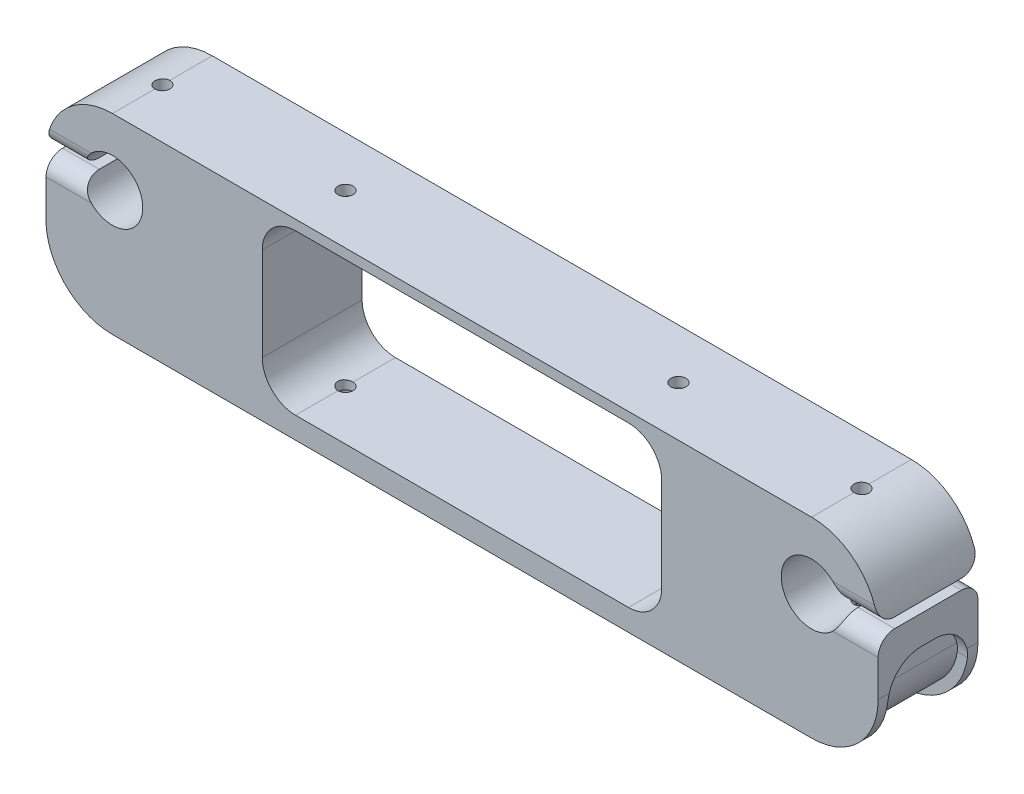
from build123d import *

# Parameters (mm, degrees)
SKETCH1_R               = 9.1
SKETCH1_R_2             = 4.125
BOSS_EXTRUDE1_DEPTH     = 30
CUT_EXTRUDE1_DEPTH      = 1
CUT_EXTRUDE1_DEPTH_BACK = 31
CUT_EXTRUDE2_DEPTH      = 12
FILLET1_R               = 10
FILLET1_OF_MIRROR1_R    = 10
SKETCH4_W               = 30
SKETCH4_H               = 3
CUT_EXTRUDE_THIN1_DEPTH = 18
FILLET2_R               = 5
SKETCH5_R               = 2.25
CUT_EXTRUDE3_DEPTH      = 60
CUT_EXTRUDE5_DEPTH      = 23
CUT_EXTRUDE6_START      = -23
SKETCH8_R               = 2.25
CUT_EXTRUDE6_DEPTH      = 100
FILLET2_OF_MIRROR2_R    = 5
SKETCH9_R               = 6.365755214
SKETCH9_R_2             = 7.364808268
BOSS_EXTRUDE2_DEPTH     = 3
SKETCH10_R              = 3.75
CUT_EXTRUDE7_DEPTH      = 4


with BuildPart() as part:
    # Sketch1 → Boss-Extrude1 (new body)
    with BuildSketch(Plane.XY):
        with BuildLine():
            Line((100.911119666, -31.68477204), (-108.97947751, -31.68477204))
            ThreePointArc((-108.97947751, -31.68477204), (-122.680198233, -26.254955692), (-128.941679221, -12.913797207))
            Line((-128.941679221, -12.913797207), (-128.941679221, 4.586502121))
            ThreePointArc((-128.941679221, 4.586502121), (-123.549540016, 19.516057921), (-108.979459083, 25.81522796))
            Line((-108.979459083, 25.81522796), (101.020540917, 25.81522796))
            ThreePointArc((101.020540917, 25.81522796), (115.16267654, 19.957363584), (121.020540917, 5.81522796))
            Line((121.020540917, 5.81522796), (121.020540917, -11.685071367))
            ThreePointArc((121.020540917, -11.685071367), (115.123937227, -25.865840476), (100.911119666, -31.68477204))
        make_face()
        with Locations((-108.979459083, 5.81522796)):
            Circle(SKETCH1_R, mode=Mode.SUBTRACT)
        with Locations((-83.979459083, 13.81522796)):
            Circle(SKETCH1_R_2, mode=Mode.SUBTRACT)
        with Locations((76.020540917, 13.81522796)):
            Circle(SKETCH1_R_2, mode=Mode.SUBTRACT)
        with Locations((101.020540917, 5.81522796)):
            Circle(SKETCH1_R, mode=Mode.SUBTRACT)
    extrude(amount=BOSS_EXTRUDE1_DEPTH)

    # Sketch2 → Cut-Extrude1 (cut, two sides)
    with BuildSketch(Plane(origin=(0, 0, 0), x_dir=(-1, 0, 0), z_dir=(0, 0, -1))) as cut_extrude1_sk:
        with BuildLine():
            Line((-46.020540917, -25.18477204), (53.979459083, -25.18477204))
            ThreePointArc((53.979459083, -25.18477204), (61.050526895, -22.255839852), (63.979459083, -15.18477204))
            Line((63.979459083, -15.18477204), (63.979459083, 12.81522796))
            ThreePointArc((63.979459083, 12.81522796), (61.050526895, 19.886295772), (53.979459083, 22.81522796))
            Line((53.979459083, 22.81522796), (-46.020540917, 22.81522796))
            ThreePointArc((-46.020540917, 22.81522796), (-53.091608729, 19.886295772), (-56.020540917, 12.81522796))
            Line((-56.020540917, 12.81522796), (-56.020540917, -15.18477204))
            ThreePointArc((-56.020540917, -15.18477204), (-53.091608729, -22.255839852), (-46.020540917, -25.18477204))
        make_face()
    extrude(amount=CUT_EXTRUDE1_DEPTH, mode=Mode.SUBTRACT)
    extrude(cut_extrude1_sk.sketch, amount=-CUT_EXTRUDE1_DEPTH_BACK, mode=Mode.SUBTRACT)

    # Sketch3 → Cut-Extrude2 (cut, symmetric)
    with BuildSketch(Plane(origin=(0, 0, 15), x_dir=(-1, 0, 0), z_dir=(0, 0, -1))):
        with BuildLine():
            Line((-121.020540917, -4.31328929), (-121.020540917, -11.685071367))
            ThreePointArc((-121.020540917, -11.685071367), (-115.123937227, -25.865840476), (-100.911119666, -31.68477204))
            Line((-100.911119666, -31.68477204), (-56.020540917, -31.68477204))
            Line((-56.020540917, -31.68477204), (-56.020540917, -28.68477204))
            Line((-56.020540917, -28.68477204), (-100.919659575, -28.68477204))
            ThreePointArc((-100.919659575, -28.68477204), (-113.005636185, -23.741500831), (-118.020540917, -11.685071367))
            Line((-118.020540917, -11.685071367), (-118.020540917, -4.31328929))
            Line((-118.020540917, -4.31328929), (-121.020540917, -4.31328929))
        make_face()
    cut_extrude2 = extrude(amount=CUT_EXTRUDE2_DEPTH, both=True, mode=Mode.SUBTRACT)

    # Fillet1
    fillet1_edges = [part.edges().sort_by_distance(p)[0] for p in [
        (119.520540917, -4.31328929, 3),
        (119.520540917, -4.31328929, 27),
        (56.020540917, -30.18477204, 3),
        (56.020540917, -30.18477204, 27),
    ]]
    fillet(fillet1_edges, radius=FILLET1_R)

    # Mirror1: Cut-Extrude2 across plane
    add(cut_extrude2.mirror(Plane(origin=(-3.979459083, 0, 0), x_dir=(0, 0, 1), z_dir=(1, 0, 0))), mode=Mode.SUBTRACT)

    # Fillet1 of Mirror1
    fillet1_of_mirror1_edges = [part.edges().sort_by_distance(p)[0] for p in [
        (-127.479459083, -4.31328929, 3),
        (-127.479459083, -4.31328929, 27),
        (-63.979459083, -30.18477204, 3),
        (-63.979459083, -30.18477204, 27),
    ]]
    fillet(fillet1_of_mirror1_edges, radius=FILLET1_OF_MIRROR1_R)

    # Sketch4 → Cut-Extrude-Thin1 (cut)
    with BuildSketch(Plane(origin=(121.020540917, 0, 0), x_dir=(0, 0, -1), z_dir=(1, 0, 0))):
        with Locations((-15, 5.81522796)):
            Rectangle(SKETCH4_W, SKETCH4_H)
    cut_extrude_thin1 = extrude(amount=-CUT_EXTRUDE_THIN1_DEPTH, mode=Mode.SUBTRACT)

    # Fillet2
    fillet2_edges = [part.edges().sort_by_distance(p)[0] for p in [
        (115.508302051, 4.31522796, 30),
        (115.480137389, 7.31522796, 30),
        (115.480137389, 7.31522796, 0),
        (115.508302051, 4.31522796, 0),
    ]]
    fillet(fillet2_edges, radius=FILLET2_R)

    # Sketch5 → Cut-Extrude3 (cut)
    with BuildSketch(Plane(origin=(0, 25.81522796, 0), x_dir=(1, 0, 0), z_dir=(0, 1, 0))):
        with Locations((101.020540917, -15)):
            Circle(SKETCH5_R)
    cut_extrude3 = extrude(amount=-CUT_EXTRUDE3_DEPTH, mode=Mode.SUBTRACT)

    # Sketch7 → Cut-Extrude5 (cut)
    with BuildSketch(Plane(origin=(0, -28.68477204, 0), x_dir=(-1, 0, 0), z_dir=(0, -1, 0))):
        Polygon((-100.960782653, -19.32971465), (-97.241018907, -17.11310515), (-97.300777171, -12.7833905), (-101.080299181, -10.67028535), (-104.800062927, -12.88689485), (-104.740304663, -17.2166095), align=None)
    cut_extrude5 = extrude(amount=-CUT_EXTRUDE5_DEPTH, mode=Mode.SUBTRACT)

    # Sketch8 → Cut-Extrude6 (cut)
    with BuildSketch(Plane.XZ.offset(-22.81522796).offset(CUT_EXTRUDE6_START)):
        with Locations((-53.979459083, 15)):
            Circle(SKETCH8_R)
    cut_extrude6 = extrude(amount=CUT_EXTRUDE6_DEPTH, mode=Mode.SUBTRACT)

    # Mirror2: Cut-Extrude-Thin1, Cut-Extrude3, Cut-Extrude5, Cut-Extrude6 across plane
    add(cut_extrude_thin1.mirror(Plane(origin=(-3.979459083, 0, 0), x_dir=(0, 0, 1), z_dir=(1, 0, 0))), mode=Mode.SUBTRACT)
    add(cut_extrude3.mirror(Plane(origin=(-3.979459083, 0, 0), x_dir=(0, 0, 1), z_dir=(1, 0, 0))), mode=Mode.SUBTRACT)
    add(cut_extrude5.mirror(Plane(origin=(-3.979459083, 0, 0), x_dir=(0, 0, 1), z_dir=(1, 0, 0))), mode=Mode.SUBTRACT)
    add(cut_extrude6.mirror(Plane(origin=(-3.979459083, 0, 0), x_dir=(0, 0, 1), z_dir=(1, 0, 0))), mode=Mode.SUBTRACT)

    # Fillet2 of Mirror2
    fillet2_of_mirror2_edges = [part.edges().sort_by_distance(p)[0] for p in [
        (-123.467220218, 4.31522796, 30),
        (-123.439055555, 7.31522796, 30),
        (-123.439055555, 7.31522796, 0),
        (-123.467220218, 4.31522796, 0),
    ]]
    fillet(fillet2_of_mirror2_edges, radius=FILLET2_OF_MIRROR2_R)

    # Sketch9 → Boss-Extrude2 (add)
    with BuildSketch(Plane.XY.offset(30)):
        with Locations((-83.979459083, 13.81522796)):
            Circle(SKETCH9_R)
        with Locations((76.020540917, 13.81522796)):
            Circle(SKETCH9_R_2)
    extrude(amount=-BOSS_EXTRUDE2_DEPTH)

    # Sketch10 → Cut-Extrude7 (cut)
    with BuildSketch(Plane(origin=(0, -31.68477204, 0), x_dir=(-1, 0, 0), z_dir=(0, -1, 0))):
        with Locations((-46.020540917, -15)):
            Circle(SKETCH10_R)
        with Locations((53.979459083, -15)):
            Circle(SKETCH10_R)
    extrude(amount=-CUT_EXTRUDE7_DEPTH, mode=Mode.SUBTRACT)


solid = part.part
